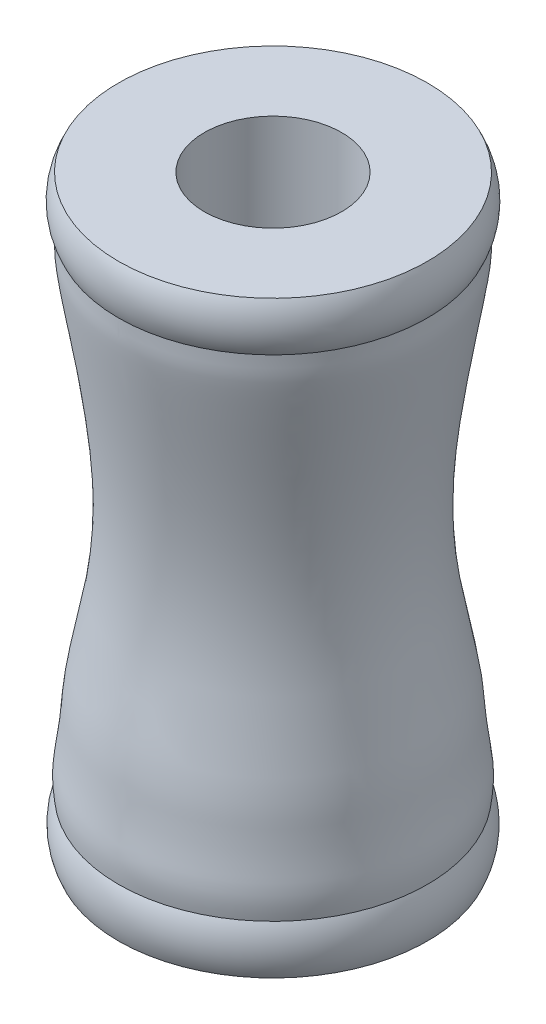
from build123d import *


with BuildPart() as part:
    # 草图1 → 旋转1 (revolve)
    with BuildSketch(Plane(origin=(0, 0, 0), x_dir=(0, 0, -1), z_dir=(1, 0, 0))):
        with BuildLine():
            Line((1.4, 4.597673683), (1.4, -5.402326317))
            Line((1.4, -5.402326317), (1.4, -6.402326317))
            Line((1.4, -6.402326317), (3.15, -6.402326317))
            ThreePointArc((3.15, -6.402326317), (3.260172476, -5.902326317), (3.15, -5.402326317))
            add(Edge.make_bspline(
                [(3.15, 4.597673683), (3.147467961, 4.351617186), (3.165090376, 4.156919407), (2.97026487, 3.069416364), (2.548580857, 0.552799712), (2.577046641, -1.463916124), (3.011916756, -3.204160398), (3.110183618, -4.770116455), (3.227447319, -4.842468449), (3.15, -5.402326317)],
                knots=[0, 0, 0, 0, 0.064611949, 0.225245532, 0.398626229, 0.622833701, 0.743358039, 0.781074669, 1, 1, 1, 1], degree=3))
            ThreePointArc((3.15, 4.597673683), (3.270891746, 5.097673683), (3.15, 5.597673683))
            Line((3.15, 5.597673683), (1.4, 5.597673683))
            Line((1.4, 5.597673683), (1.4, 4.597673683))
        make_face()
    revolve(axis=Axis((0, 0, 0), (0, -1, 0)))


solid = part.part
